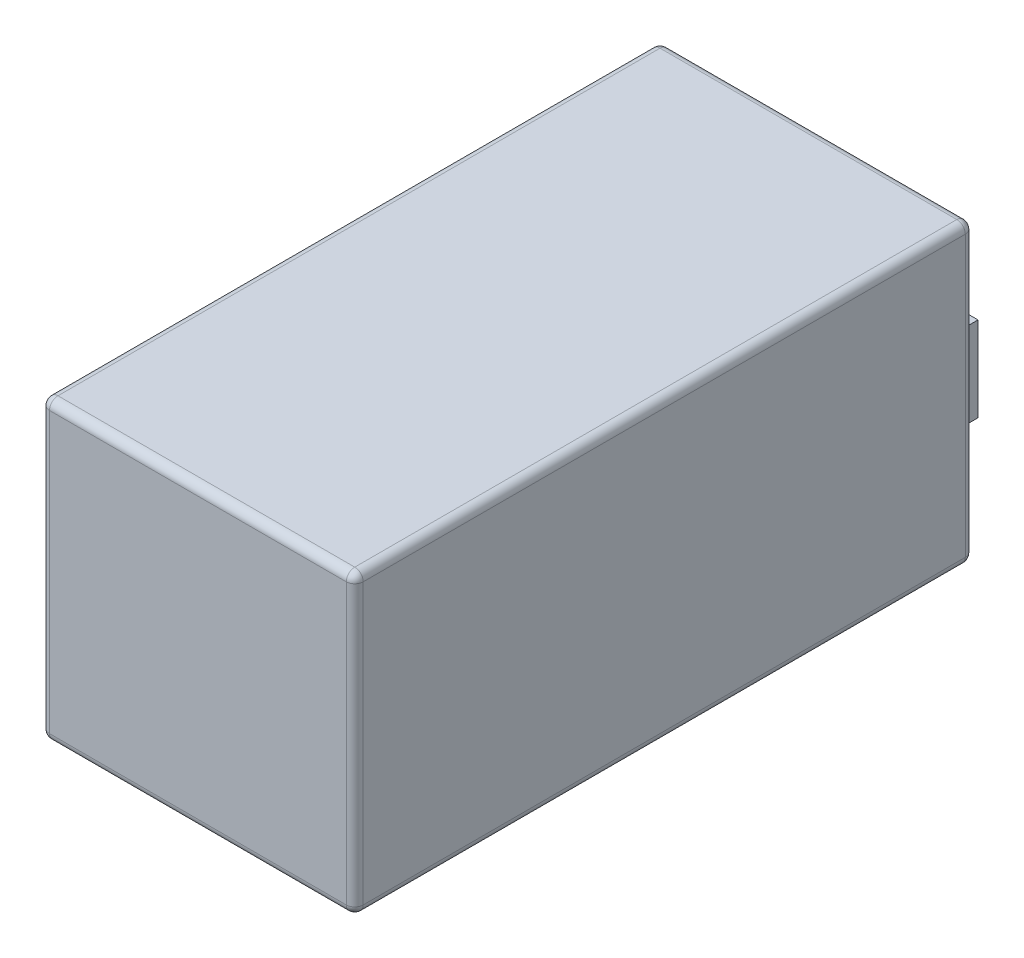
from build123d import *

# Parameters (mm, degrees)
SKETCH1_W           = 37
SKETCH1_H           = 73
BOSS_EXTRUDE1_DEPTH = 17.5
SKETCH2_W           = 4
SKETCH2_H           = 10
BOSS_EXTRUDE2_DEPTH = 2.5
FILLET1_R           = 1


with BuildPart() as part:
    # Sketch1 → Boss-Extrude1 (new body, symmetric)
    with BuildSketch(Plane(origin=(0, 0, 0), x_dir=(1, 0, 0), z_dir=(0, 1, 0))):
        Rectangle(SKETCH1_W, SKETCH1_H)
    extrude(amount=BOSS_EXTRUDE1_DEPTH, both=True)

    # Sketch2 → Boss-Extrude2 (add, symmetric)
    with BuildSketch(Plane(origin=(0, 0, -36.5), x_dir=(-1, 0, 0), z_dir=(0, 0, -1))):
        with Locations((-14.5, 0)):
            Rectangle(SKETCH2_W, SKETCH2_H)
    extrude(amount=BOSS_EXTRUDE2_DEPTH, both=True)

    # Fillet1
    fillet1_edges = [part.edges().sort_by_distance(p)[0] for p in [
        (-18.5, 17.5, 0),
        (0, 17.5, 36.5),
        (18.5, 17.5, 0),
        (0, -17.5, 36.5),
        (-18.5, -17.5, 0),
        (0, -17.5, -36.5),
        (18.5, -17.5, 0),
        (18.5, 0, 36.5),
        (-18.5, 0, 36.5),
        (-18.5, 0, -36.5),
        (18.5, 0, -36.5),
        (0, 17.5, -36.5),
    ]]
    fillet(fillet1_edges, radius=FILLET1_R)


solid = part.part
